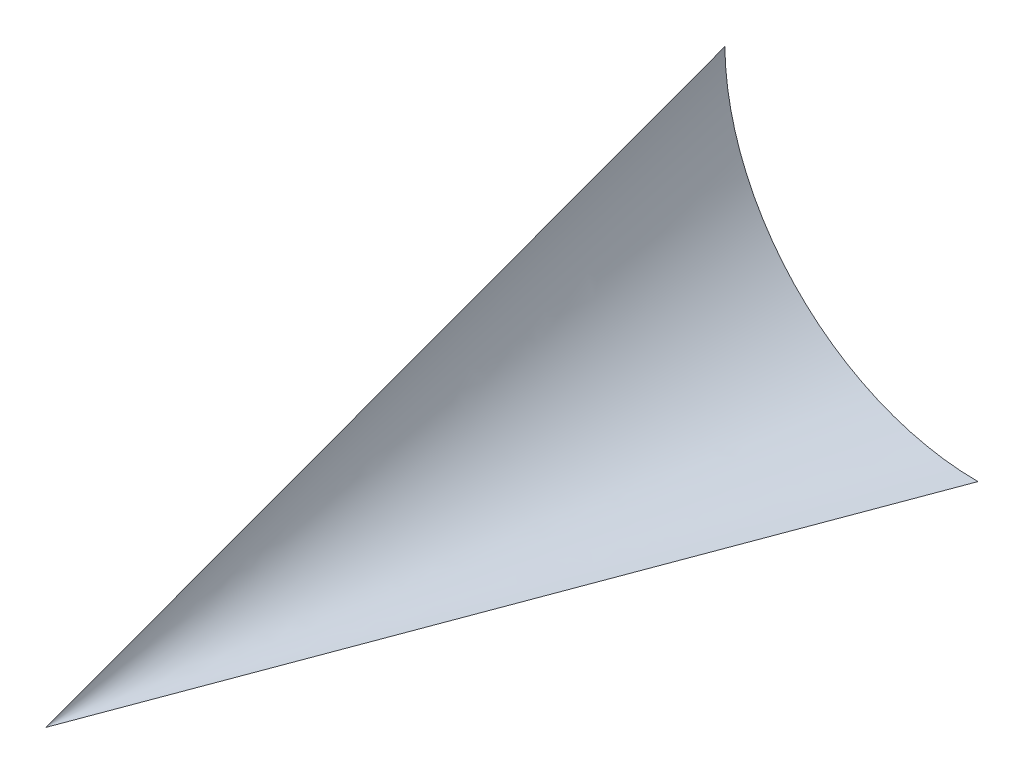
from build123d import *


with BuildPart() as part:
    # Esquisse1 → Lissage1 section 0
    with BuildSketch(Plane.XY, mode=Mode.PRIVATE) as lissage1_s0:
        with BuildLine():
            Line((0, 55.10960961), (0, 0))
            Line((0, 0), (55.78294362, 0))
            ThreePointArc((55.78294362, 0), (16.575782698, 16.100859618), (0, 55.10960961))
        make_face()
    loft([Vertex(0, 0, 149.576865659), lissage1_s0.sketch])


solid = part.part
